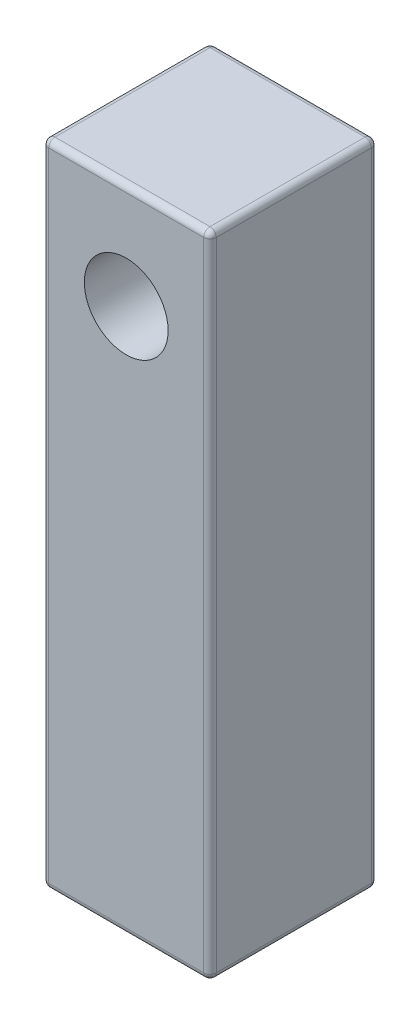
from build123d import *

# Parameters (mm, degrees)
SKIZZE1_W                       = 8
SKIZZE1_H                       = 8
AUFSATZ_LINEAR_AUSTRAGEN1_DEPTH = 31
VERRUNDUNG1_R                   = 0.3
SKIZZE2_R                       = 2
SCHNITT_LINEAR_AUSTRAGEN1_DEPTH = 9


with BuildPart() as part:
    # Skizze1 → Aufsatz-Linear austragen1 (new body)
    with BuildSketch(Plane(origin=(0, 0, 0), x_dir=(1, 0, 0), z_dir=(0, 1, 0))):
        Rectangle(SKIZZE1_W, SKIZZE1_H)
    extrude(amount=AUFSATZ_LINEAR_AUSTRAGEN1_DEPTH)

    # Verrundung1
    verrundung1_edges = [part.edges().sort_by_distance(p)[0] for p in [
        (-4, 31, 0),
        (0, 31, 4),
        (4, 31, 0),
        (0, 0, 4),
        (-4, 0, 0),
        (0, 0, -4),
        (4, 0, 0),
        (0, 31, -4),
        (4, 15.5, 4),
        (-4, 15.5, 4),
        (-4, 15.5, -4),
        (4, 15.5, -4),
    ]]
    fillet(verrundung1_edges, radius=VERRUNDUNG1_R)

    # Skizze2 → Schnitt-Linear austragen1 (cut, through all)
    with BuildSketch(Plane.XY.offset(4)):
        with Locations((0, 26)):
            Circle(SKIZZE2_R)
    extrude(amount=-SCHNITT_LINEAR_AUSTRAGEN1_DEPTH, mode=Mode.SUBTRACT)


solid = part.part
